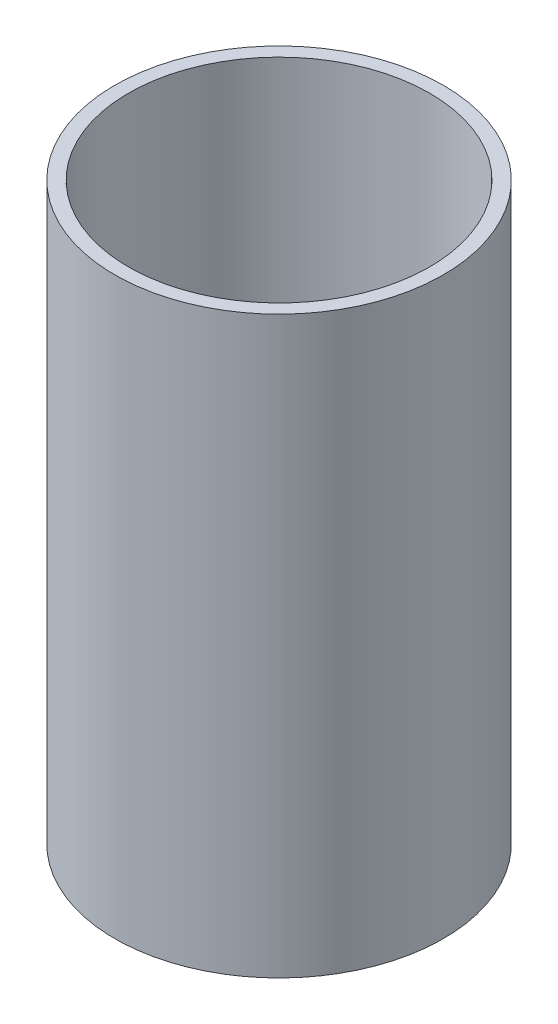
from build123d import *

# Parameters (mm, degrees)
SKETCH1_W = 1
SKETCH1_H = 42


with BuildPart() as part:
    # Sketch1 → Revolve1 (revolve)
    with BuildSketch(Plane.XY):
        with Locations((11.5, 21)):
            Rectangle(SKETCH1_W, SKETCH1_H)
    revolve(axis=Axis((0, 0, 0), (0, 1, 0)))


solid = part.part
